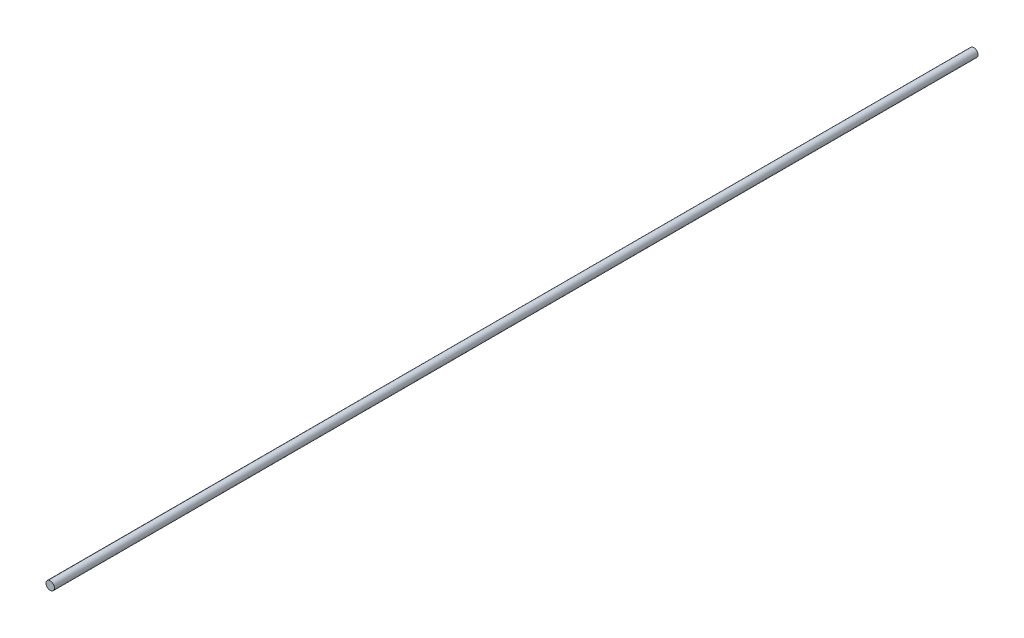
from build123d import *

# Parameters (mm, degrees)
SKETCH1_R           = 1.5
BOSS_EXTRUDE1_DEPTH = 330


with BuildPart() as part:
    # Sketch1 → Boss-Extrude1 (new body)
    with BuildSketch(Plane.XY):
        Circle(SKETCH1_R)
    extrude(amount=BOSS_EXTRUDE1_DEPTH)


solid = part.part
